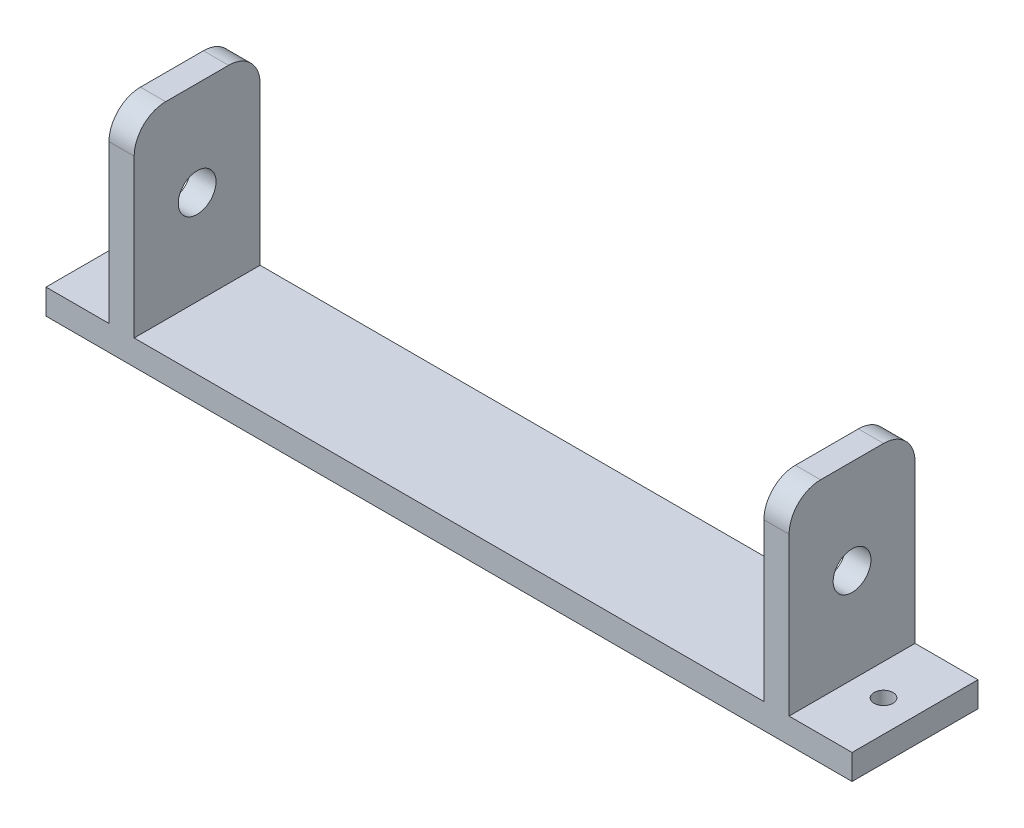
from build123d import *

# Parameters (mm, degrees)
BOSS_EXTRUDE1_DEPTH = 20
SKETCH2_R           = 3
CUT_EXTRUDE1_DEPTH  = 4
SKETCH3_R           = 3
CUT_EXTRUDE2_DEPTH  = 4
FILLET1_R           = 5
SKETCH4_W           = 20
SKETCH4_H           = 4
BOSS_EXTRUDE2_DEPTH = 10
SKETCH5_W           = 20
SKETCH5_H           = 4
BOSS_EXTRUDE3_DEPTH = 10
SKETCH6_R           = 1.5
CUT_EXTRUDE3_DEPTH  = 4


with BuildPart() as part:
    # Sketch1 → Boss-Extrude1 (new body)
    with BuildSketch(Plane.XY):
        Polygon((-89.731830747, 25.752777778), (-89.731830747, -4.247222222), (10.268169253, -4.247222222), (10.268169253, 25.752777778), (14.268169253, 25.752777778), (14.268169253, -8.247222222), (-93.731830747, -8.247222222), (-93.731830747, 25.752777778), align=None)
    extrude(amount=BOSS_EXTRUDE1_DEPTH)

    # Sketch2 → Cut-Extrude1 (cut)
    with BuildSketch(Plane.ZY.offset(93.731830747)):
        with Locations((10, 10.752777778)):
            Circle(SKETCH2_R)
    extrude(amount=-CUT_EXTRUDE1_DEPTH, mode=Mode.SUBTRACT)

    # Sketch3 → Cut-Extrude2 (cut)
    with BuildSketch(Plane(origin=(14.268169253, 0, 0), x_dir=(0, 0, -1), z_dir=(1, 0, 0))):
        with Locations((-10, 10.752777778)):
            Circle(SKETCH3_R)
    extrude(amount=-CUT_EXTRUDE2_DEPTH, mode=Mode.SUBTRACT)

    # Fillet1
    fillet1_edges = [part.edges().sort_by_distance(p)[0] for p in [
        (-91.731830747, 25.752777778, 0),
        (12.268169253, 25.752777778, 20),
        (-91.731830747, 25.752777778, 20),
        (12.268169253, 25.752777778, 0),
    ]]
    fillet(fillet1_edges, radius=FILLET1_R)

    # Sketch4 → Boss-Extrude2 (add)
    with BuildSketch(Plane(origin=(14.268169253, 0, 0), x_dir=(0, 0, -1), z_dir=(1, 0, 0))):
        with Locations((-10, -6.247222222)):
            Rectangle(SKETCH4_W, SKETCH4_H)
    extrude(amount=BOSS_EXTRUDE2_DEPTH)

    # Sketch5 → Boss-Extrude3 (add)
    with BuildSketch(Plane.ZY.offset(93.731830747)):
        with Locations((10, -6.247222222)):
            Rectangle(SKETCH5_W, SKETCH5_H)
    extrude(amount=BOSS_EXTRUDE3_DEPTH)

    # Sketch6 → Cut-Extrude3 (cut)
    with BuildSketch(Plane(origin=(0, -4.247222222, 0), x_dir=(1, 0, 0), z_dir=(0, 1, 0))):
        with Locations((-98.731830747, -10)):
            Circle(SKETCH6_R)
        with Locations((19.268169253, -10)):
            Circle(SKETCH6_R)
    extrude(amount=-CUT_EXTRUDE3_DEPTH, mode=Mode.SUBTRACT)


solid = part.part
